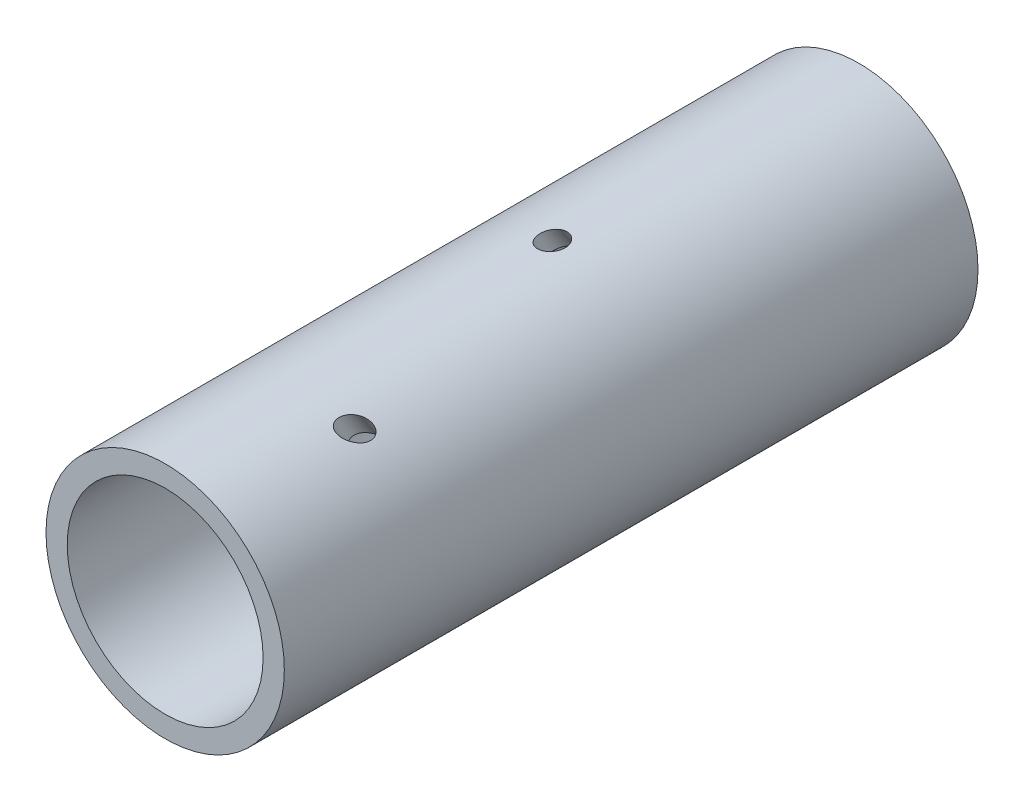
from build123d import *

# Parameters (mm, degrees)
SKIZZE1_R                       = 27.484712029
SKIZZE1_R_2                     = 22.58736277
AUFSATZ_LINEAR_AUSTRAGEN1_DEPTH = 160


with BuildPart() as part:
    # Skizze1 → Aufsatz-Linear austragen1 (new body)
    with BuildSketch(Plane.XY):
        Circle(SKIZZE1_R)
        Circle(SKIZZE1_R_2, mode=Mode.SUBTRACT)
    extrude(amount=-AUFSATZ_LINEAR_AUSTRAGEN1_DEPTH)

    # Skizze6 → Ø6.0 (6) Durchmesser Bohrung2 (revolve, cut)
    with BuildSketch(Plane(origin=(0, 0, -107.118504804), x_dir=(0, 0.544639035, -0.838670568), z_dir=(1, 0, 0))):
        Polygon((0, 0), (0, 83.113387119), (2.865, 81.391921446), (2.865, 0), align=None)
    revolve(axis=Axis((0, -5.325558106, -110.576962677), (0, 0.838670568, 0.544639035)), mode=Mode.SUBTRACT)

    # Skizze9 → Ø6.0 (6) Durchmesser Bohrung3 (revolve, cut)
    with BuildSketch(Plane(origin=(12, -1.983133308, -48.982393542), x_dir=(0, 0.544639035, -0.838670568), z_dir=(1, 0, 0))):
        Polygon((0, 0), (0, 53.059309664), (2.775, 51.391921446), (2.775, 0), align=None)
    revolve(axis=Axis((12, -7.308691414, -52.440851414), (0, 0.838670568, 0.544639035)), mode=Mode.SUBTRACT)


solid = part.part
